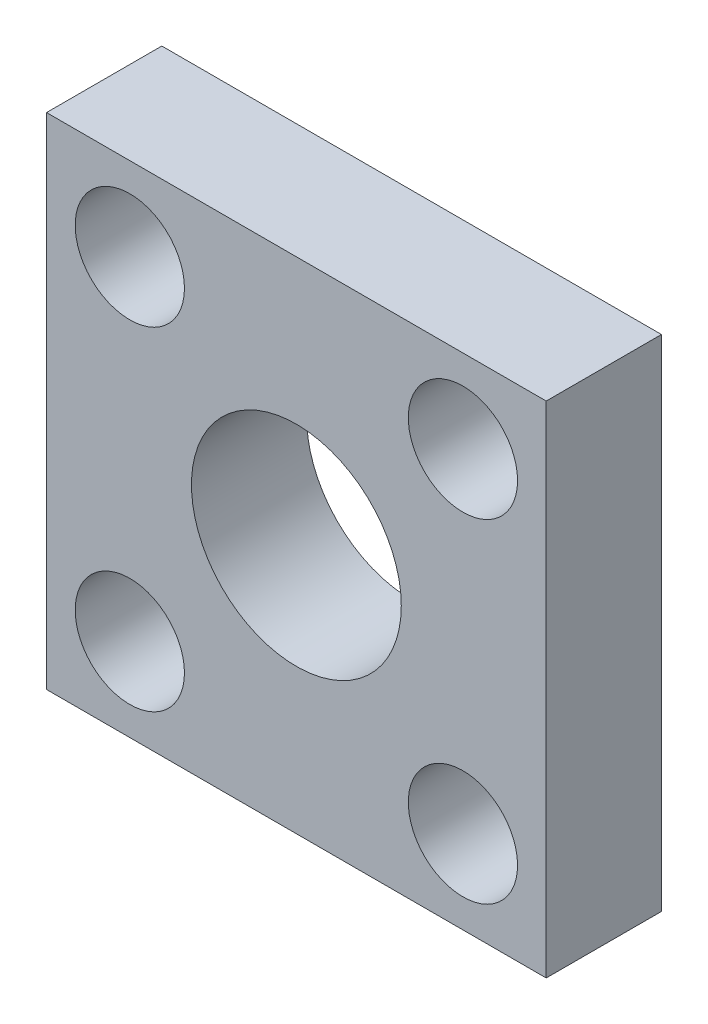
from build123d import *

# Parameters (mm, degrees)
SKETCH1_W           = 19.05
SKETCH1_H           = 19.05
SKETCH1_R           = 2.0828
SKETCH1_R_2         = 4
BOSS_EXTRUDE1_DEPTH = 4.3942


with BuildPart() as part:
    # Sketch1 → Boss-Extrude1 (new body)
    with BuildSketch(Plane.XY):
        with Locations((9.525, 9.525)):
            Rectangle(SKETCH1_W, SKETCH1_H)
        with Locations((3.175, 3.175)):
            Circle(SKETCH1_R, mode=Mode.SUBTRACT)
        with Locations((3.175, 15.875)):
            Circle(SKETCH1_R, mode=Mode.SUBTRACT)
        with Locations((15.875, 15.875)):
            Circle(SKETCH1_R, mode=Mode.SUBTRACT)
        with Locations((15.875, 3.175)):
            Circle(SKETCH1_R, mode=Mode.SUBTRACT)
        with Locations((9.525, 9.525)):
            Circle(SKETCH1_R_2, mode=Mode.SUBTRACT)
    extrude(amount=BOSS_EXTRUDE1_DEPTH)


solid = part.part
